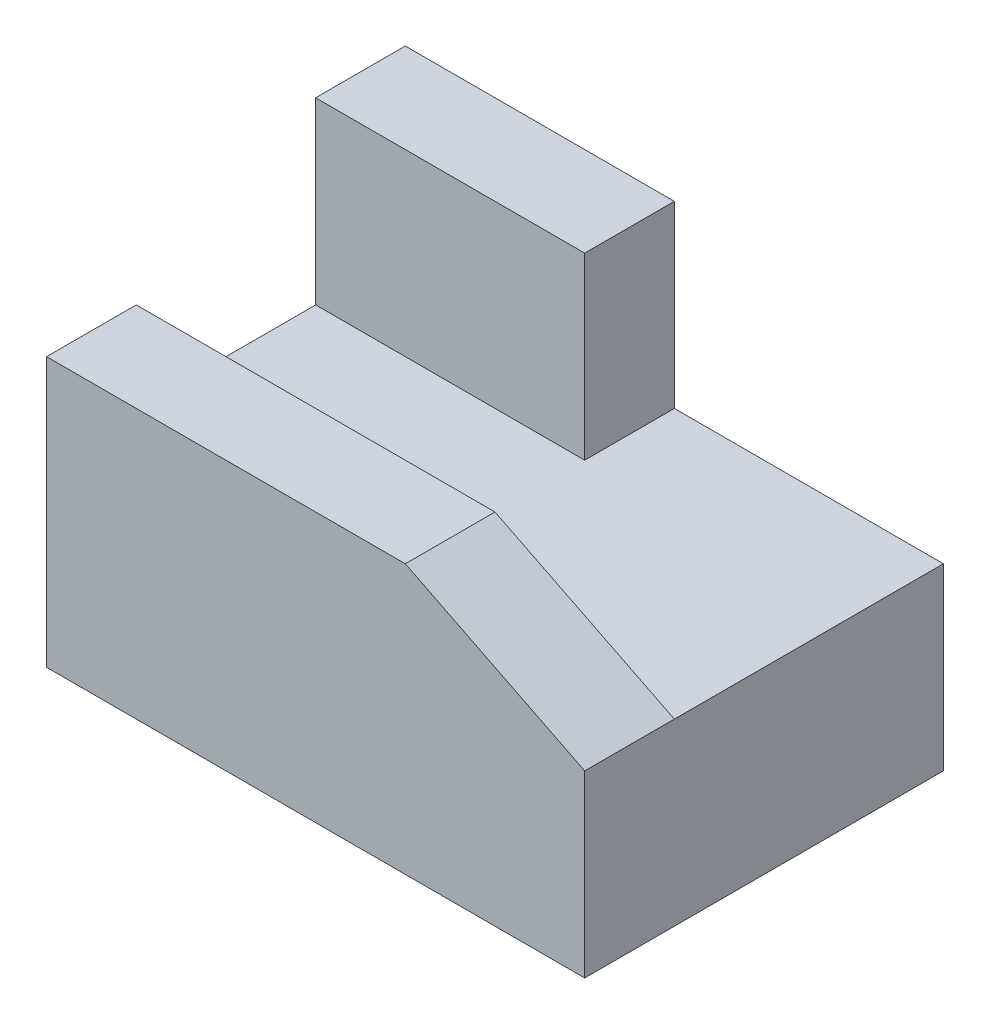
from build123d import *

# Parameters (mm, degrees)
SKETCH_1_W          = 30
SKETCH_1_H          = 20
EXTRUDE_1_DEPTH     = 10
SKETCH_1_3_W        = 30
SKETCH_1_3_H        = 5
EXTRUDE_2_DEPTH     = 15
SKETCH_1_4_W        = 15
SKETCH_1_4_H        = 5
EXTRUDE_3_DEPTH     = 20
CUT_EXTRUDE_1_DEPTH = 20


with BuildPart() as part:
    # 草圖1 → 填料-伸長1 (new body)
    with BuildSketch(Plane(origin=(0, 0, 0), x_dir=(1, 0, 0), z_dir=(0, 1, 0))):
        Rectangle(SKETCH_1_W, SKETCH_1_H)
    extrude(amount=EXTRUDE_1_DEPTH)

    # 草圖1<3> → 填料-伸長2 (add)
    with BuildSketch(Plane(origin=(0, 0, 0), x_dir=(1, 0, 0), z_dir=(0, 1, 0))):
        with Locations((0, -7.5)):
            Rectangle(SKETCH_1_3_W, SKETCH_1_3_H)
    extrude(amount=EXTRUDE_2_DEPTH)

    # 草圖1<4> → 填料-伸長3 (add)
    with BuildSketch(Plane(origin=(0, 0, 0), x_dir=(1, 0, 0), z_dir=(0, 1, 0))):
        with Locations((-7.5, 7.5)):
            Rectangle(SKETCH_1_4_W, SKETCH_1_4_H)
    extrude(amount=EXTRUDE_3_DEPTH)

    # 草圖2 → 除料-伸長1 (cut)
    with BuildSketch(Plane.XY.offset(10)):
        Polygon((5, 15), (15, 10), (15, 15), align=None)
    extrude(amount=-CUT_EXTRUDE_1_DEPTH, mode=Mode.SUBTRACT)


solid = part.part
